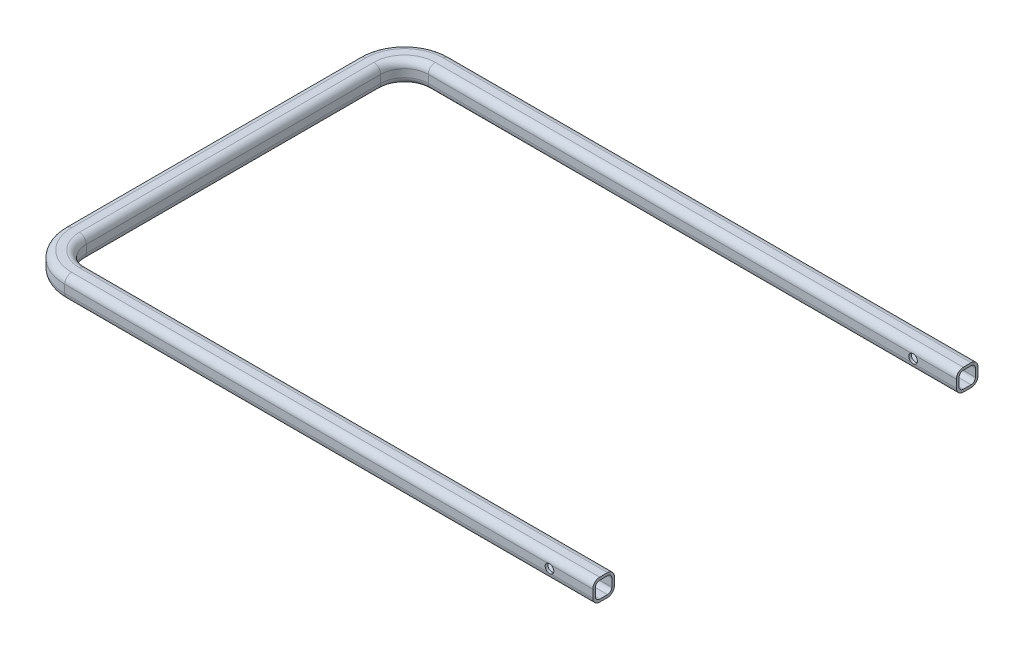
from build123d import *

# Parameters (mm, degrees)
SKETCH3_R               = 5
CUT_EXTRUDE1_DEPTH      = 13.5000001
CUT_EXTRUDE1_DEPTH_BACK = 433.5000001


with BuildPart() as part:
    # Sweep-Thin1: sweep along a path in Sketch1
    with BuildLine(Plane(origin=(0, 0, 0), x_dir=(1, 0, 0), z_dir=(0, 1, 0))) as sweep_thin1_path:
        Line((0, 0), (-610, 0))
        ThreePointArc((-610, 0), (-638.284271247, 11.715728753), (-650, 40))
        Line((-650, 40), (-650, 380))
        ThreePointArc((-650, 380), (-638.284271247, 408.284271247), (-610, 420))
        Line((-610, 420), (0, 420))
    # Sketch2 → Sweep-Thin1 (sweep)
    with BuildSketch(Plane(origin=(0, 0, 0), x_dir=(0, 0, -1), z_dir=(1, 0, 0))):
        with BuildLine():
            Line((4.5, 12.5), (-4.5, 12.5))
            ThreePointArc((-4.5, 12.5), (-10.156854249, 10.156854249), (-12.5, 4.5))
            Line((-12.5, 4.5), (-12.5, -4.5))
            ThreePointArc((-12.5, -4.5), (-10.156854249, -10.156854249), (-4.5, -12.5))
            Line((-4.5, -12.5), (4.5, -12.5))
            ThreePointArc((4.5, -12.5), (10.156854249, -10.156854249), (12.5, -4.5))
            Line((12.5, -4.5), (12.5, 4.5))
            ThreePointArc((12.5, 4.5), (10.156854249, 10.156854249), (4.5, 12.5))
        make_face()
        with BuildLine():
            Line((4.5, 9.5), (-4.5, 9.5))
            ThreePointArc((-4.5, 9.5), (-8.035533906, 8.035533906), (-9.5, 4.5))
            Line((-9.5, 4.5), (-9.5, -4.5))
            ThreePointArc((-9.5, -4.5), (-8.035533906, -8.035533906), (-4.5, -9.5))
            Line((-4.5, -9.5), (4.5, -9.5))
            ThreePointArc((4.5, -9.5), (8.035533906, -8.035533906), (9.5, -4.5))
            Line((9.5, -4.5), (9.5, 4.5))
            ThreePointArc((9.5, 4.5), (8.035533906, 8.035533906), (4.5, 9.5))
        make_face(mode=Mode.SUBTRACT)
    sweep(path=sweep_thin1_path.line)

    # Sketch3 → Cut-Extrude1 (cut, two sides)
    with BuildSketch(Plane.XY) as cut_extrude1_sk:
        with Locations((-50, 0)):
            Circle(SKETCH3_R)
    extrude(amount=CUT_EXTRUDE1_DEPTH, mode=Mode.SUBTRACT)
    extrude(cut_extrude1_sk.sketch, amount=-CUT_EXTRUDE1_DEPTH_BACK, mode=Mode.SUBTRACT)


solid = part.part
